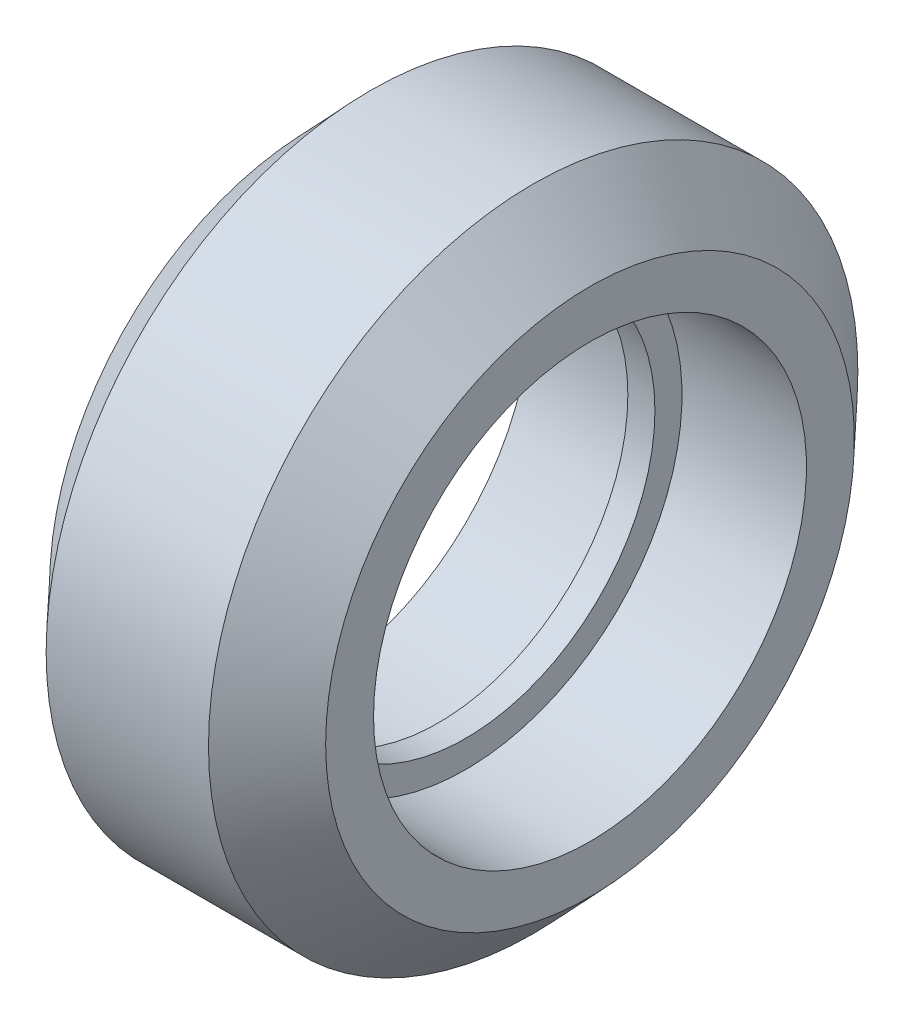
from build123d import *


with BuildPart() as part:
    # Sketch1 → Revolve1 (revolve)
    with BuildSketch(Plane.XY):
        Polygon((-3, 12), (3, 12), (5.1, 9.77), (5.1, 8), (0.5, 8), (0.5, 7), (-0.5, 7), (-0.5, 8), (-5.1, 8), (-5.1, 9.77), align=None)
    revolve(axis=Axis((-3.433522218, 0, 0), (1, 0, 0)))


solid = part.part
